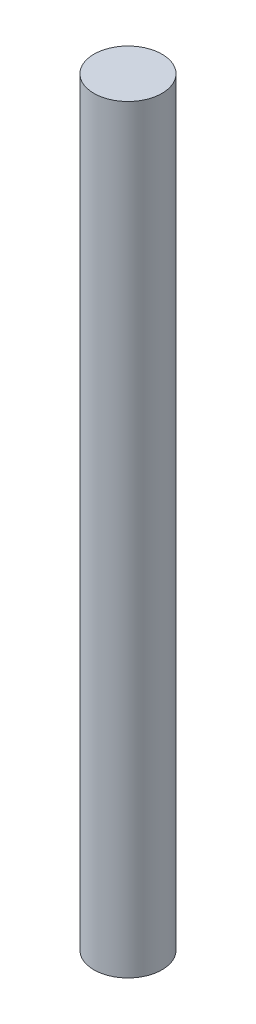
from build123d import *

# Parameters (mm, degrees)
SKETCH2_R           = 1.075
BOSS_EXTRUDE1_DEPTH = 24


with BuildPart() as part:
    # Sketch2 → Boss-Extrude1 (new body)
    with BuildSketch(Plane(origin=(0, 0, 0), x_dir=(1, 0, 0), z_dir=(0, 1, 0))):
        Circle(SKETCH2_R)
    extrude(amount=BOSS_EXTRUDE1_DEPTH)


solid = part.part
